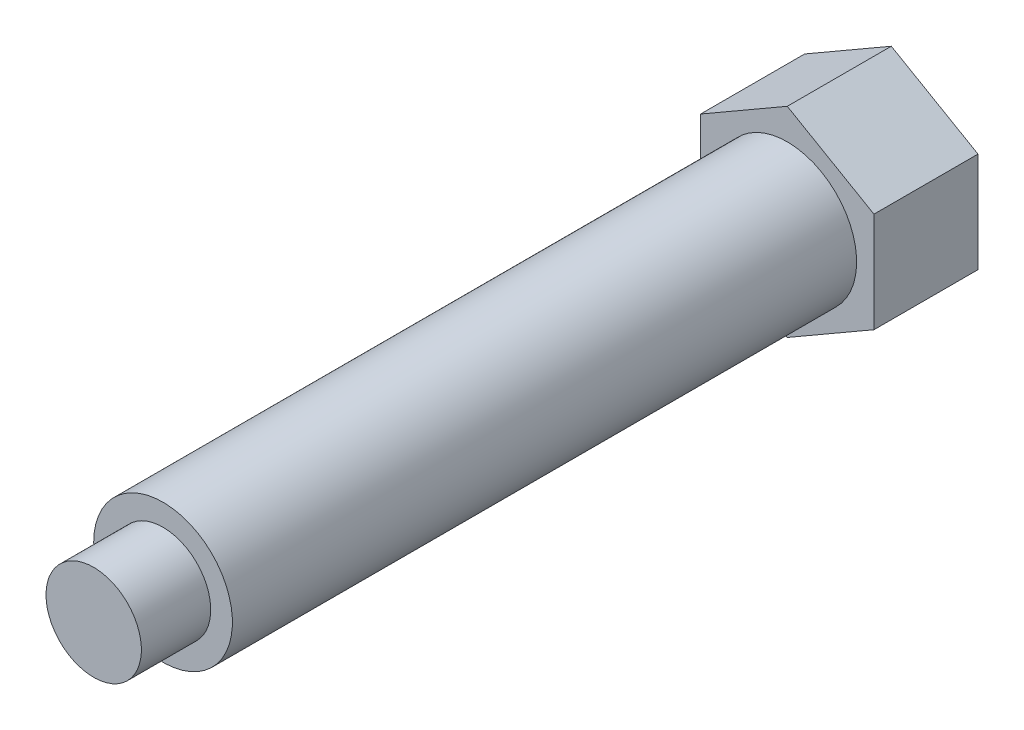
from build123d import *

# Parameters (mm, degrees)
BOSS_EXTRUDE1_DEPTH = 6


with BuildPart() as part:
    # Sketch1 → Base-Revolve (revolve)
    with BuildSketch(Plane(origin=(0, 0, 0), x_dir=(1, 0, 0), z_dir=(0, 1, 0))):
        Polygon((0, 0), (0, -40), (2.75, -40), (2.75, -36), (4, -36), (4, 0), align=None)
    revolve(axis=Axis((0, 0, -1.187299328), (0, 0, 1)))

    # Sketch2 → Boss-Extrude1 (add)
    with BuildSketch(Plane(origin=(0, 0, 0), x_dir=(-1, 0, 0), z_dir=(0, 0, -1))):
        Polygon((5, -2.886751346), (5, 2.886751346), (0, 5.773502692), (-5, 2.886751346), (-5, -2.886751346), (0, -5.773502692), align=None)
    extrude(amount=BOSS_EXTRUDE1_DEPTH)


solid = part.part
